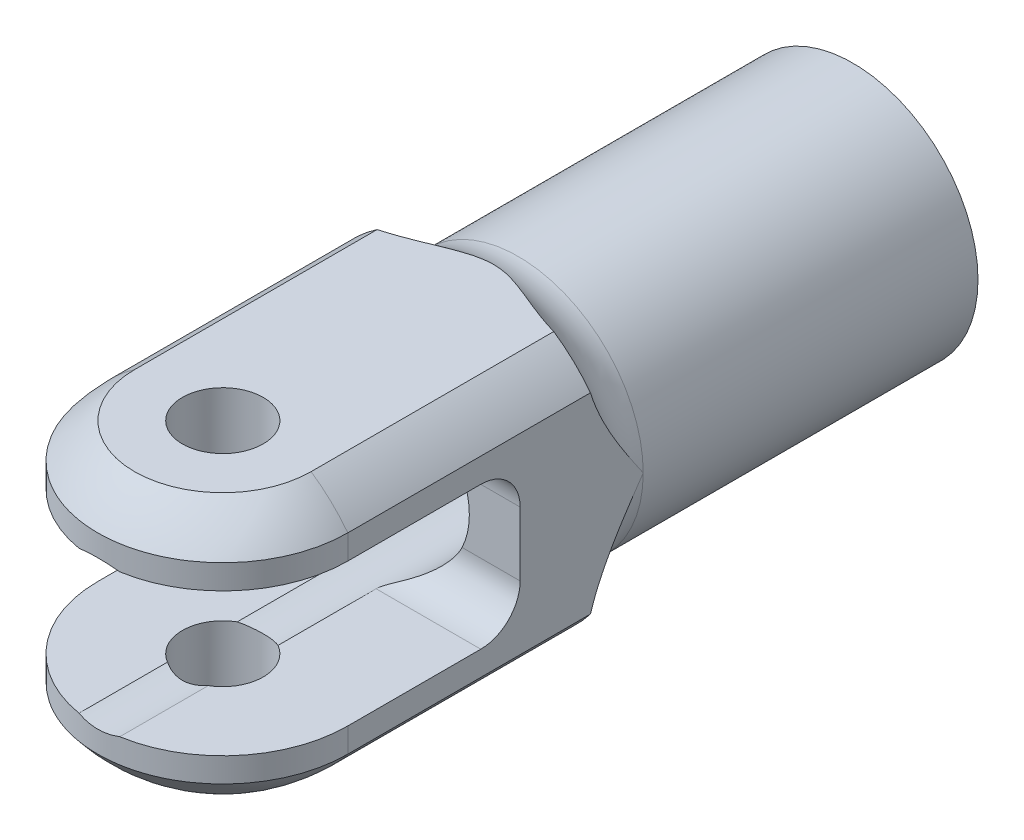
from build123d import *

# Parameters (mm, degrees)
SKETCH1_R               = 12.7
EXTRUDE1_DEPTH          = 90
BOSS_EXTRUDE1_START     = -40
SKETCH11_R              = 18.9
BOSS_EXTRUDE1_DEPTH     = 50
FILLET1_R               = 6
SKETCH2_OUTSIDE_W       = 60.736
SKETCH2_OUTSIDE_H       = 112.936
SKETCH2_OUTSIDE_R       = 4.1021
EXTRUDE3_DEPTH          = 19.9
EXTRUDE3_DEPTH_BACK     = 19.9
EXTRUDE4_DEPTH          = 13.7000001
EXTRUDE4_DEPTH_BACK     = 13.7000001
EXTRUDE5_START          = 8
SKETCH7_R               = 7.54
EXTRUDE5_DEPTH          = 69.700000104
SKETCH8_R               = 5
CUT_EXTRUDE1_DEPTH      = 47.5
SKETCH12_W              = 59.539598316
SKETCH12_H              = 14.810845352
CUT_EXTRUDE2_DEPTH      = 13.7000001
CUT_EXTRUDE2_DEPTH_BACK = 13.7000001
SKETCH13_OUTSIDE_W      = 44.406
SKETCH13_OUTSIDE_H      = 45.506
SKETCH13_OUTSIDE_R      = 16
CUT_EXTRUDE3_DEPTH      = 77.700000101


with BuildPart() as part:
    # Sketch1 → Extrude1 (new body)
    with BuildSketch(Plane.XY):
        Circle(SKETCH1_R)
    extrude(amount=EXTRUDE1_DEPTH)

    # Sketch11 → Boss-Extrude1 (add)
    with BuildSketch(Plane(origin=(0, 0, 0), x_dir=(-1, 0, 0), z_dir=(0, 0, -1)).offset(BOSS_EXTRUDE1_START)):
        Circle(SKETCH11_R)
    extrude(amount=-BOSS_EXTRUDE1_DEPTH)

    # Fillet1
    fillet1_edges = [part.edges().sort_by_distance(p)[0] for p in [
        (-12.7, 0, 40),
    ]]
    fillet(fillet1_edges, radius=FILLET1_R)

    # Sketch2 outside → Extrude3 (cut, two sides)
    with BuildSketch(Plane(origin=(0, 0, 0), x_dir=(1, 0, 0), z_dir=(0, 1, 0))) as extrude3_sk:
        with Locations((0, -45)):
            Rectangle(SKETCH2_OUTSIDE_W, SKETCH2_OUTSIDE_H)
        with BuildLine():
            Line((12.7, 0), (-12.7, 0))
            Line((-12.7, 0), (-12.7, -64))
            ThreePointArc((-12.7, -64), (0, -76.7), (12.7, -64))
            Line((12.7, -64), (12.7, 0))
        make_face(mode=Mode.SUBTRACT)
        with Locations((0, -64)):
            Circle(SKETCH2_OUTSIDE_R)
    extrude(amount=EXTRUDE3_DEPTH, mode=Mode.SUBTRACT)
    extrude(extrude3_sk.sketch, amount=-EXTRUDE3_DEPTH_BACK, mode=Mode.SUBTRACT)

    # Sketch3 → Extrude4 (cut, two sides)
    with BuildSketch(Plane(origin=(0, 0, 0), x_dir=(0, 0, -1), z_dir=(1, 0, 0))) as extrude4_sk:
        with BuildLine():
            Line((-106.9, 7.25), (-50.5, 7.25))
            ThreePointArc((-50.5, 7.25), (-47.671572875, 6.078427125), (-46.5, 3.25))
            Line((-46.5, 3.25), (-46.5, -3.25))
            ThreePointArc((-46.5, -3.25), (-47.671572875, -6.078427125), (-50.5, -7.25))
            Line((-50.5, -7.25), (-106.9, -7.25))
            Line((-106.9, -7.25), (-106.9, 7.25))
        make_face()
    extrude(amount=EXTRUDE4_DEPTH, mode=Mode.SUBTRACT)
    extrude(extrude4_sk.sketch, amount=-EXTRUDE4_DEPTH_BACK, mode=Mode.SUBTRACT)

    # Sketch7 → Extrude5 (cut, through all)
    with BuildSketch(Plane.XY.offset(EXTRUDE5_START)):
        Circle(SKETCH7_R)
    extrude(amount=EXTRUDE5_DEPTH, mode=Mode.SUBTRACT)

    # Sketch8 → Cut-Extrude1 (cut, through all)
    with BuildSketch(Plane.XY.offset(46.5)):
        Circle(SKETCH8_R)
    extrude(amount=-CUT_EXTRUDE1_DEPTH, mode=Mode.SUBTRACT)

    # Sketch12 → Cut-Extrude2 (cut, two sides)
    with BuildSketch(Plane(origin=(0, 0, 0), x_dir=(0, 0, -1), z_dir=(1, 0, 0))) as cut_extrude2_sk:
        with Locations((-55.382472155, 20.655422676)):
            Rectangle(SKETCH12_W, SKETCH12_H)
        with Locations((-55.382472155, -20.655422676)):
            Rectangle(SKETCH12_W, SKETCH12_H)
    extrude(amount=CUT_EXTRUDE2_DEPTH, mode=Mode.SUBTRACT)
    extrude(cut_extrude2_sk.sketch, amount=-CUT_EXTRUDE2_DEPTH_BACK, mode=Mode.SUBTRACT)

    # Sketch13 outside → Cut-Extrude3 (cut, through all)
    with BuildSketch(Plane.XY):
        Rectangle(SKETCH13_OUTSIDE_W, SKETCH13_OUTSIDE_H)
        Circle(SKETCH13_OUTSIDE_R, mode=Mode.SUBTRACT)
    extrude(amount=CUT_EXTRUDE3_DEPTH, mode=Mode.SUBTRACT)

    # Sketch14 → Cut-Revolve1 (revolve, cut)
    with BuildSketch(Plane(origin=(0, 0, 0), x_dir=(0, 0, -1), z_dir=(1, 0, 0))):
        with BuildLine():
            Line((-64, 16), (-64, 21.221837108))
            Line((-64, 21.221837108), (-91.217828515, 21.221837108))
            Line((-91.217828515, 21.221837108), (-91.217828515, 0))
            Line((-91.217828515, 0), (-80, 0))
            ThreePointArc((-80, 0), (-75.313708499, 11.313708499), (-64, 16))
        make_face()
    revolve(axis=Axis((0, 0, 64), (0, 0, 1)), mode=Mode.SUBTRACT)


solid = part.part
